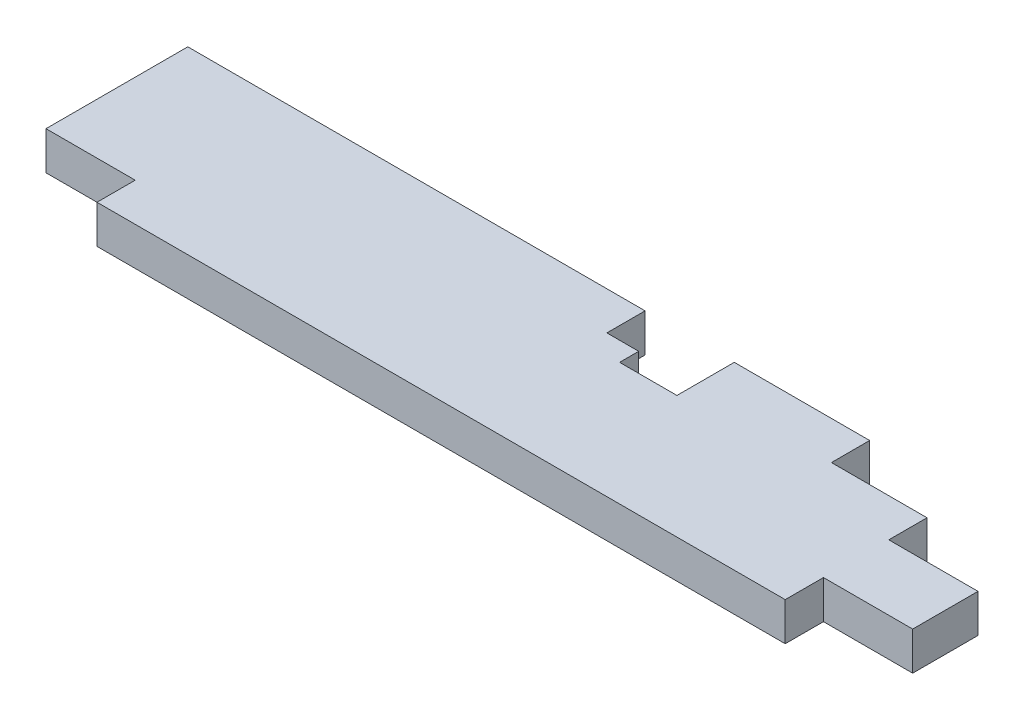
from build123d import *

# Parameters (mm, degrees)
SKETCH1_W           = 863.6
SKETCH1_H           = 179.3875
BOSS_EXTRUDE1_DEPTH = 38.1
SKETCH2_W           = 88.9
SKETCH2_H           = 38.1
CUT_EXTRUDE4_DEPTH  = 39.1
SKETCH3_W           = 184.15
SKETCH3_H           = 38.1
CUT_EXTRUDE1_DEPTH  = 39.1
CUT_EXTRUDE2_DEPTH  = 39.1
SKETCH5_W           = 88.9
SKETCH5_H           = 38.1
CUT_EXTRUDE3_DEPTH  = 39.1
SKETCH6_W           = 88.9
SKETCH6_H           = 38.1
CUT_EXTRUDE5_DEPTH  = 39.1


with BuildPart() as part:
    # Sketch1 → Boss-Extrude1 (new body)
    with BuildSketch(Plane(origin=(0, 0, 0), x_dir=(1, 0, 0), z_dir=(0, 1, 0))):
        with Locations((431.8, 89.69375)):
            Rectangle(SKETCH1_W, SKETCH1_H)
    extrude(amount=BOSS_EXTRUDE1_DEPTH)

    # Sketch2 → Cut-Extrude4 (cut, through all)
    with BuildSketch(Plane.XZ):
        with Locations((819.15, -19.05)):
            Rectangle(SKETCH2_W, SKETCH2_H)
    extrude(amount=-CUT_EXTRUDE4_DEPTH, mode=Mode.SUBTRACT)

    # Sketch3 → Cut-Extrude1 (cut, through all)
    with BuildSketch(Plane.XZ):
        with Locations((771.525, -160.3375)):
            Rectangle(SKETCH3_W, SKETCH3_H)
    extrude(amount=-CUT_EXTRUDE1_DEPTH, mode=Mode.SUBTRACT)

    # Sketch4 → Cut-Extrude2 (cut, through all)
    with BuildSketch(Plane.XZ):
        Polygon((544.56454079, -179.3875), (544.56454079, -122.2375), (487.426, -122.2375), (487.426, -141.2875), (455.676, -141.2875), (455.676, -179.3875), align=None)
    extrude(amount=-CUT_EXTRUDE2_DEPTH, mode=Mode.SUBTRACT)

    # Sketch5 → Cut-Extrude3 (cut, through all)
    with BuildSketch(Plane.XZ):
        with Locations((819.15, -122.2375)):
            Rectangle(SKETCH5_W, SKETCH5_H)
    extrude(amount=-CUT_EXTRUDE3_DEPTH, mode=Mode.SUBTRACT)

    # Sketch6 → Cut-Extrude5 (cut, through all)
    with BuildSketch(Plane(origin=(0, 38.1, 0), x_dir=(1, 0, 0), z_dir=(0, 1, 0))):
        with Locations((44.45, 19.05)):
            Rectangle(SKETCH6_W, SKETCH6_H)
    extrude(amount=-CUT_EXTRUDE5_DEPTH, mode=Mode.SUBTRACT)


solid = part.part
